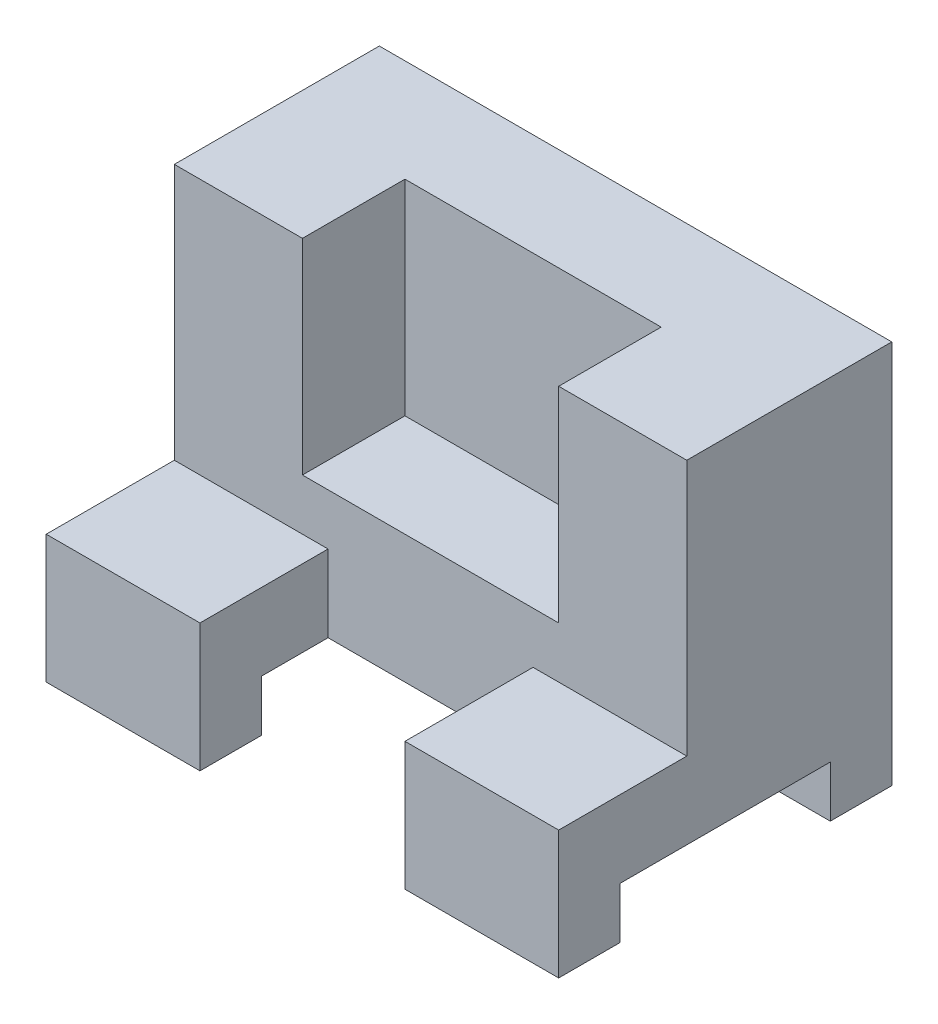
from build123d import *

# Parameters (mm, degrees)
SKETCH1_W               = 100
SKETCH1_H               = 65
BOSS_EXTRUDE1_DEPTH     = 75
SKETCH5_W               = 41
SKETCH5_H               = 10
CUT_EXTRUDE1_DEPTH      = 141
SKETCH6_OUTSIDE_W       = 130.178
SKETCH6_OUTSIDE_H       = 95.178
SKETCH6_OUTSIDE_W_2     = 100
SKETCH6_OUTSIDE_H_2     = 40
CUT_EXTRUDE2_DEPTH      = 1
CUT_EXTRUDE2_DEPTH_BACK = 50
SKETCH7_W               = 50
SKETCH7_H               = 20
CUT_EXTRUDE3_DEPTH      = 40
SKETCH10_W              = 40
SKETCH10_H              = 25
CUT_EXTRUDE4_DEPTH      = 40


with BuildPart() as part:
    # Sketch1 → Boss-Extrude1 (new body)
    with BuildSketch(Plane(origin=(0, 0, 0), x_dir=(1, 0, 0), z_dir=(0, 1, 0))):
        with Locations((-6.156156156, 9.992492492)):
            Rectangle(SKETCH1_W, SKETCH1_H)
    extrude(amount=BOSS_EXTRUDE1_DEPTH)

    # Sketch5 → Cut-Extrude1 (cut)
    with BuildSketch(Plane(origin=(43.843843844, 0, 0), x_dir=(0, 0, -1), z_dir=(1, 0, 0))):
        with Locations((9.992492492, 5)):
            Rectangle(SKETCH5_W, SKETCH5_H)
    extrude(amount=-CUT_EXTRUDE1_DEPTH, mode=Mode.SUBTRACT)

    # Sketch6 outside → Cut-Extrude2 (cut, two sides)
    with BuildSketch(Plane(origin=(0, 75, 0), x_dir=(1, 0, 0), z_dir=(0, 1, 0))) as cut_extrude2_sk:
        with Locations((-6.156, 9.992)):
            Rectangle(SKETCH6_OUTSIDE_W, SKETCH6_OUTSIDE_H)
        with Locations((-6.156156156, 22.492492492)):
            Rectangle(SKETCH6_OUTSIDE_W_2, SKETCH6_OUTSIDE_H_2, mode=Mode.SUBTRACT)
    extrude(amount=CUT_EXTRUDE2_DEPTH, mode=Mode.SUBTRACT)
    extrude(cut_extrude2_sk.sketch, amount=-CUT_EXTRUDE2_DEPTH_BACK, mode=Mode.SUBTRACT)

    # Sketch7 → Cut-Extrude3 (cut)
    with BuildSketch(Plane(origin=(0, 75, 0), x_dir=(1, 0, 0), z_dir=(0, 1, 0))):
        with Locations((-6.156156156, 12.492492492)):
            Rectangle(SKETCH7_W, SKETCH7_H)
    extrude(amount=-CUT_EXTRUDE3_DEPTH, mode=Mode.SUBTRACT)

    # Sketch10 → Cut-Extrude4 (cut)
    with BuildSketch(Plane(origin=(0, 25, 0), x_dir=(1, 0, 0), z_dir=(0, 1, 0))):
        with Locations((-6.156156156, -10.007507508)):
            Rectangle(SKETCH10_W, SKETCH10_H)
    extrude(amount=-CUT_EXTRUDE4_DEPTH, mode=Mode.SUBTRACT)


solid = part.part
